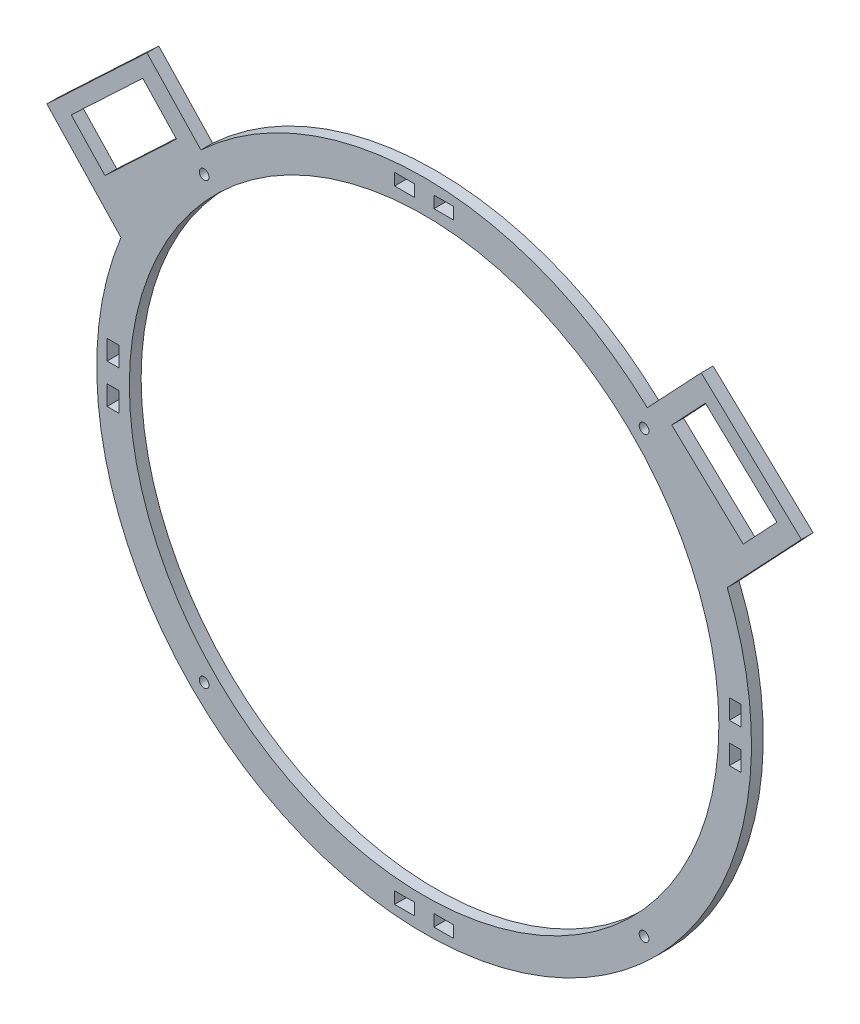
from build123d import *

# Parameters (mm, degrees)
SALIENTE_EXTRUIR1_DEPTH = 6
CROQUIS2_W              = 10
CROQUIS2_H              = 6
CROQUIS2_W_2            = 6
CROQUIS2_H_2            = 10
CORTAR_EXTRUIR1_DEPTH   = 10


with BuildPart() as part:
    # Croquis1 → Saliente-Extruir1 (new body)
    with BuildSketch(Plane.XY):
        with BuildLine():
            ThreePointArc((267.780622857, -36.999917491), (154.190797134, 7.728122029), (40.600971411, -36.999917491))
            Line((40.600971411, -36.999917491), (13.169180469, -7.88811841))
            Line((13.169180469, -7.88811841), (5.891230699, -14.746066146))
            Line((5.891230699, -14.746066146), (-37.776467922, -55.893752559))
            Line((-37.776467922, -55.893752559), (-0.057755376, -95.922476295))
            ThreePointArc((-0.057755376, -95.922476295), (154.190797134, -325.468820804), (308.439349644, -95.922476295))
            Line((308.439349644, -95.922476295), (346.15806219, -55.893752559))
            Line((346.15806219, -55.893752559), (302.490363569, -14.746066146))
            Line((302.490363569, -14.746066146), (295.212413799, -7.88811841))
            Line((295.212413799, -7.88811841), (267.780622857, -36.999917491))
        make_face()
        with BuildLine():
            ThreePointArc((50.939396199, -50.062499464), (51.321581101, -49.701102835), (51.705030941, -49.341048614))
            ThreePointArc((51.705030941, -49.341048614), (213.886421224, -21.26063874), (304.190797134, -158.870349387))
            ThreePointArc((304.190797134, -158.870349387), (94.978087942, -296.688545102), (50.939396199, -50.062499464))
        make_face(mode=Mode.SUBTRACT)
        Polygon((-25.35505735, -54.494267151), (11.034691501, -20.204528474), (28.17956084, -38.399402899), (-8.210188011, -72.689141577), align=None, mode=Mode.SUBTRACT)
        Polygon((316.591782279, -72.689141577), (280.202033428, -38.399402899), (297.346902767, -20.204528474), (333.736651618, -54.494267151), align=None, mode=Mode.SUBTRACT)
    extrude(amount=SALIENTE_EXTRUIR1_DEPTH)

    # Croquis2 → Cortar-Extruir1 (cut)
    with BuildSketch(Plane.XY.offset(6)):
        Polygon((139.190797134, -3.571113679), (149.190797134, -3.571113679), (149.190797134, -0.571113679), (149.190797134, 2.428886321), (139.190797134, 2.428886321), align=None)
        with Locations((164.190797134, -0.571113679)):
            Rectangle(CROQUIS2_W, CROQUIS2_H)
        with Locations((312.490032842, -148.870349387)):
            Rectangle(CROQUIS2_W_2, CROQUIS2_H_2)
        Polygon((312.490032842, -163.870349387), (315.490032842, -163.870349387), (315.490032842, -173.870349387), (309.490032842, -173.870349387), (309.490032842, -163.870349387), align=None)
        with Locations((164.190797134, -317.169585095)):
            Rectangle(CROQUIS2_W, CROQUIS2_H)
        Polygon((149.190797134, -317.169585095), (149.190797134, -314.169585095), (139.190797134, -314.169585095), (139.190797134, -320.169585095), (149.190797134, -320.169585095), align=None)
        with Locations((-4.108438574, -148.870349387)):
            Rectangle(CROQUIS2_W_2, CROQUIS2_H_2)
        Polygon((-7.108438574, -173.870349387), (-7.108438574, -163.870349387), (-4.108438574, -163.870349387), (-1.108438574, -163.870349387), (-1.108438574, -173.870349387), align=None)
        with BuildLine():
            ThreePointArc((40.506244825, -45.185797078), (40.506244825, -48.685975645), (44.006423391, -48.685975645))
            Line((44.006423391, -48.685975645), (40.506244825, -45.185797078))
        make_face()
        with BuildLine():
            Line((40.506244825, -45.185797078), (44.006423391, -48.685975645))
            ThreePointArc((44.006423391, -48.685975645), (44.542935951, -47.883027856), (44.731334108, -46.935886361))
            ThreePointArc((44.731334108, -46.935886361), (43.203475603, -44.649284518), (40.506244825, -45.185797078))
        make_face()
        with BuildLine():
            ThreePointArc((267.875349443, -45.185797078), (264.375170876, -45.185797078), (264.375170876, -48.685975645))
            Line((264.375170876, -48.685975645), (267.875349443, -45.185797078))
        make_face()
        with BuildLine():
            Line((267.875349443, -45.185797078), (264.375170876, -48.685975645))
            ThreePointArc((264.375170876, -48.685975645), (267.072401655, -49.222488204), (268.60026016, -46.935886361))
            ThreePointArc((268.60026016, -46.935886361), (268.411862003, -45.988744866), (267.875349443, -45.185797078))
        make_face()
        with BuildLine():
            ThreePointArc((268.60026016, -270.804812413), (267.072401655, -268.51821057), (264.375170876, -269.05472313))
            Line((264.375170876, -269.05472313), (267.875349443, -272.554901696))
            ThreePointArc((267.875349443, -272.554901696), (268.411862003, -271.751953908), (268.60026016, -270.804812413))
        make_face()
        with BuildLine():
            Line((267.875349443, -272.554901696), (264.375170876, -269.05472313))
            ThreePointArc((264.375170876, -269.05472313), (264.375170876, -272.554901696), (267.875349443, -272.554901696))
        make_face()
        with BuildLine():
            ThreePointArc((44.731334108, -270.804812413), (44.542935951, -269.857670918), (44.006423391, -269.05472313))
            Line((44.006423391, -269.05472313), (40.506244825, -272.554901696))
            ThreePointArc((40.506244825, -272.554901696), (43.203475603, -273.091414256), (44.731334108, -270.804812413))
        make_face()
        with BuildLine():
            Line((40.506244825, -272.554901696), (44.006423391, -269.05472313))
            ThreePointArc((44.006423391, -269.05472313), (40.506244825, -269.05472313), (40.506244825, -272.554901696))
        make_face()
    extrude(amount=-CORTAR_EXTRUIR1_DEPTH, mode=Mode.SUBTRACT)


solid = part.part
